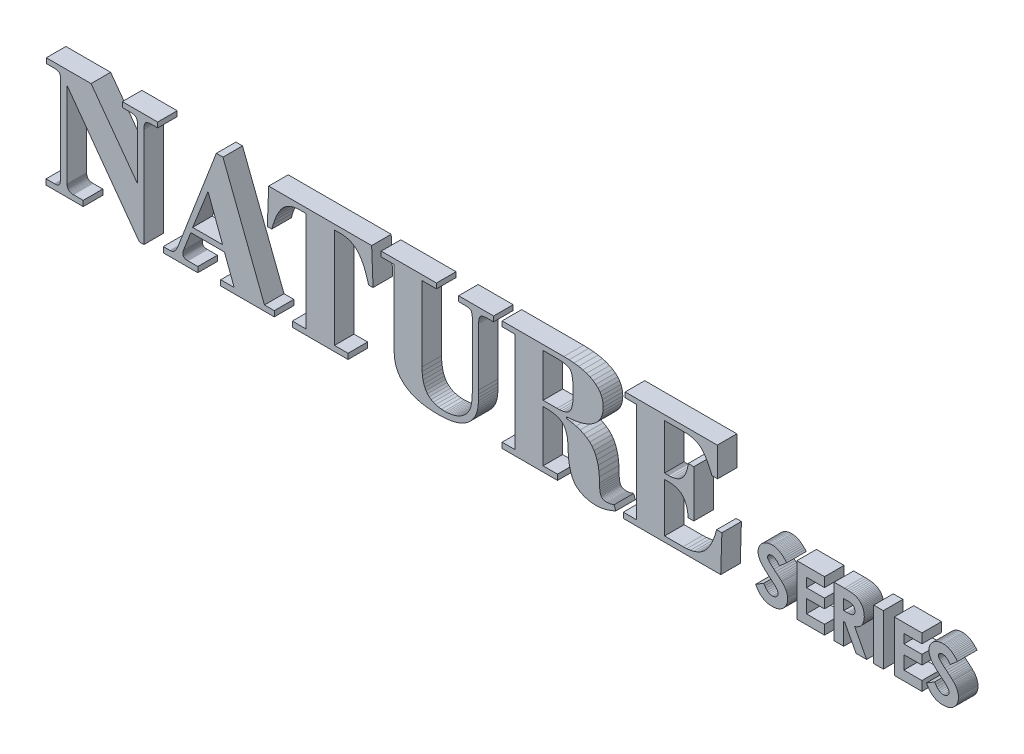
from build123d import *

# Parameters (mm, degrees)
SKETCH2_W              = 1.472974277
SKETCH2_H              = 7.776418359
BOSS_EXTRUDE1_DEPTH    = 3
BOSS_EXTRUDE1_2_DEPTH  = 3
BOSS_EXTRUDE1_3_DEPTH  = 3
BOSS_EXTRUDE1_4_DEPTH  = 3
BOSS_EXTRUDE1_5_DEPTH  = 3
BOSS_EXTRUDE1_6_DEPTH  = 3
BOSS_EXTRUDE1_7_DEPTH  = 3
BOSS_EXTRUDE1_8_DEPTH  = 3
BOSS_EXTRUDE1_9_DEPTH  = 3
BOSS_EXTRUDE1_10_DEPTH = 3
BOSS_EXTRUDE1_11_DEPTH = 3
BOSS_EXTRUDE1_12_DEPTH = 3


with BuildPart() as part:
    # Sketch2 → Boss-Extrude1 (new body)
    with BuildSketch(Plane.XY):
        with Locations((190.243141385, 72.091281059)):
            Rectangle(SKETCH2_W, SKETCH2_H)
    extrude(amount=BOSS_EXTRUDE1_DEPTH)


with BuildPart() as body_2:
    # Sketch2 → Boss-Extrude1 2 (new body)
    with BuildSketch(Plane.XY):
        Polygon((196.902143299, 75.979490238), (192.656556863, 75.979490238), (192.656556863, 68.203071879), (196.902143299, 68.203071879), (196.902143299, 69.654380502), (194.129531141, 69.654380502), (194.129531141, 71.701332768), (196.902143299, 71.701332768), (196.902143299, 73.130975736), (194.129531141, 73.130975736), (194.129531141, 74.528170453), (196.902143299, 74.528170453), align=None)
    extrude(amount=BOSS_EXTRUDE1_2_DEPTH)


with BuildPart() as body_3:
    # Sketch2 → Boss-Extrude1 3 (new body)
    with BuildSketch(Plane.XY):
        Polygon((66.0872556, 69.295395024), (66.011950364, 69.359511059), (65.946226302, 69.432671396), (65.890618724, 69.514264821), (65.845125773, 69.604218894), (65.809745596, 69.702461174), (65.784476338, 69.808919223), (65.769316143, 69.9235206), (65.764263157, 70.046192865), (65.764263157, 83.136511986), (76.851072942, 67.890477006), (77.550708377, 67.890477006), (77.550708377, 83.188672524), (77.555754529, 83.389525472), (77.570840917, 83.571156683), (77.595889439, 83.733487662), (77.630821993, 83.876439919), (77.675560475, 83.999934958), (77.730026785, 84.103894289), (77.79414282, 84.188239418), (77.87105444, 84.25743418), (77.964002008, 84.315977166), (78.073063529, 84.363870718), (78.198317008, 84.40111718), (78.339840449, 84.427718895), (78.497711857, 84.443678206), (78.672009236, 84.448997455), (79.662875267, 84.448997455), (79.662875267, 85.231271566), (74.239066795, 85.231271566), (74.239066795, 84.448997455), (75.334237156, 84.448997455), (75.546569228, 84.443957454), (75.736555277, 84.428886784), (75.904193547, 84.403859447), (76.04948228, 84.368949445), (76.172419719, 84.324230781), (76.273004106, 84.269777455), (76.351233685, 84.205663471), (76.413498502, 84.125833008), (76.466188669, 84.024181956), (76.509302528, 83.900711877), (76.542838419, 83.755424331), (76.566794681, 83.588320883), (76.581169656, 83.399403093), (76.585961683, 83.188672524), (76.585961683, 75.470006918), (69.44532033, 85.231271566), (62.582944783, 85.231271566), (62.582944783, 84.448997455), (63.62596577, 84.448997455), (63.813560052, 84.445525388), (63.981549115, 84.435058291), (64.130005397, 84.417519819), (64.25900134, 84.392833626), (64.368609381, 84.360923368), (64.458901962, 84.3217127), (64.529951522, 84.275125277), (64.587137937, 84.218981364), (64.635740722, 84.147409919), (64.675681776, 84.060408989), (64.706882996, 83.957976622), (64.729266279, 83.840110865), (64.742753525, 83.706809765), (64.747266629, 83.558071371), (64.747266629, 70.211347436), (64.74327419, 70.033860687), (64.731298044, 69.87393249), (64.711339948, 69.731564991), (64.68340166, 69.60676034), (64.647484937, 69.499520683), (64.603591537, 69.409848169), (64.551723216, 69.337744945), (64.487833027, 69.278946696), (64.411637051, 69.229188973), (64.32305543, 69.188473731), (64.222008303, 69.156802922), (64.108415811, 69.134178498), (63.982198096, 69.120602411), (63.843275296, 69.116076615), (62.530795408, 69.116076615), (62.530795408, 68.281664291), (68.241486834, 68.281664291), (68.241486834, 69.116076615), (66.729110311, 69.116076615), (66.599493667, 69.121122767), (66.478938444, 69.136209156), (66.367440833, 69.161257677), (66.264997027, 69.196190231), (66.171603219, 69.240928714), align=None)
    extrude(amount=BOSS_EXTRUDE1_3_DEPTH)


with BuildPart() as body_4:
    # Sketch2 → Boss-Extrude1 4 (new body)
    with BuildSketch(Plane.XY):
        Polygon((109.015866431, 84.252634115), (109.386983788, 84.099902908), (109.732331023, 83.903530716), (110.051988095, 83.663515978), (110.346034959, 83.379857133), (110.619834847, 83.044072864), (110.882374835, 82.647610001), (111.133580824, 82.190474012), (111.373378714, 81.672670365), (111.601694406, 81.094204525), (111.818453799, 80.455081961), (112.023582796, 79.755308139), (112.701653035, 79.755308139), (112.484337928, 85.231271566), (96.686403611, 85.231271566), (96.482153753, 79.755308139), (97.160117952, 79.755308139), (97.375137831, 80.475032881), (97.599273898, 81.129311084), (97.832604452, 81.718140796), (98.07520779, 82.241520063), (98.32716221, 82.699446935), (98.588546008, 83.091919457), (98.859437483, 83.418935678), (99.147847531, 83.692209173), (99.465370476, 83.923444342), (99.811855579, 84.112639818), (100.187152105, 84.259794234), (100.591109315, 84.364906223), (101.023576472, 84.427974419), (101.48440284, 84.448997455), (102.401459422, 84.448997455), (102.401459422, 69.116076615), (100.315305828, 69.116076615), (100.315305828, 68.281664291), (108.868389339, 68.281664291), (108.868389339, 69.116076615), (106.782246907, 69.116076615), (106.782246907, 84.448997455), (107.747094061, 84.448997455), (108.196001525, 84.427179827), (108.618898996, 84.361725901), align=None)
    extrude(amount=BOSS_EXTRUDE1_4_DEPTH)


with BuildPart() as body_5:
    # Sketch2 → Boss-Extrude1 5 (new body)
    with BuildSketch(Plane.XY):
        Polygon((181.957719676, 75.979490238), (177.712122078, 75.979490238), (177.712122078, 68.203071879), (181.957719676, 68.203071879), (181.957719676, 69.654380502), (179.185096356, 69.654380502), (179.185096356, 71.701332768), (181.957719676, 71.701332768), (181.957719676, 73.130975736), (179.185096356, 73.130975736), (179.185096356, 74.528170453), (181.957719676, 74.528170453), align=None)
    extrude(amount=BOSS_EXTRUDE1_5_DEPTH)


with BuildPart() as body_6:
    # Sketch2 → Boss-Extrude1 6 (new body)
    with BuildSketch(Plane.XY):
        Polygon((84.110900761, 69.125771054), (84.025436427, 69.137998054), (83.946283338, 69.155241756), (83.87359028, 69.177574794), (83.807506036, 69.205069803), (83.748179393, 69.237799418), (83.69607024, 69.27343359), (83.651555748, 69.313334486), (83.614789777, 69.357501716), (83.58592619, 69.40593489), (83.565118846, 69.458633616), (83.552521609, 69.515597505), (83.548288338, 69.576826166), (83.548808401, 69.637200161), (83.550316653, 69.69536933), (83.552735186, 69.751261038), (83.555986093, 69.80480265), (83.559991468, 69.855921531), (83.564673403, 69.904545046), (83.569953992, 69.950600561), (83.575831998, 69.993929591), (83.582316956, 70.034366497), (83.589483453, 70.07168439), (83.597406078, 70.105656383), (83.606159417, 70.136055591), (83.615818058, 70.162655125), (83.62645659, 70.1852281), (84.747757449, 73.07966352), (89.906560701, 73.07966352), (91.39727157, 69.116076615), (89.332900833, 69.116076615), (89.332900833, 68.281664291), (97.546946434, 68.281664291), (97.546946434, 69.116076615), (96.043175897, 69.116076615), (89.676185926, 85.570298315), (88.659183816, 85.570298315), (82.835481614, 70.415602875), (82.751945901, 70.214429642), (82.66894138, 70.031882228), (82.586466198, 69.867962584), (82.504518498, 69.722672663), (82.423096426, 69.596014418), (82.342198127, 69.487989801), (82.261821746, 69.398600766), (82.180430817, 69.324091733), (82.092719759, 69.260841526), (81.998766381, 69.208924538), (81.898648492, 69.16841516), (81.792443901, 69.139387786), (81.680230418, 69.121916807), (81.562085853, 69.116076615), (80.519064866, 69.116076615), (80.519064866, 68.281664291), (85.816908934, 68.281664291), (85.816908934, 69.116076615), (84.300168025, 69.116076615), (84.202527555, 69.118488119), align=None)
        Polygon((85.025928377, 73.914176303), (89.624036551, 73.914176303), (87.385793636, 79.855253666), align=None, mode=Mode.SUBTRACT)
    extrude(amount=BOSS_EXTRUDE1_6_DEPTH)


with BuildPart() as body_7:
    # Sketch2 → Boss-Extrude1 7 (new body)
    with BuildSketch(Plane.XY):
        Polygon((187.14751607, 71.931744739), (187.305524027, 72.043141777), (187.448404169, 72.164923482), (187.576193008, 72.297089463), (187.688927059, 72.43963933), (187.785940368, 72.59181663), (187.868118551, 72.754346966), (187.935428804, 72.927199877), (187.987838325, 73.110344904), (188.02531431, 73.303751587), (188.047823956, 73.507389465), (188.055334461, 73.72122808), (188.048490298, 73.926032253), (188.027977075, 74.122690168), (187.993823688, 74.311233068), (187.946059037, 74.491692192), (187.884712019, 74.664098781), (187.809811532, 74.828484077), (187.721386473, 74.98487932), (187.621925505, 75.131167127), (187.513771954, 75.265250485), (187.396865878, 75.387062032), (187.271147333, 75.496534403), (187.136556376, 75.593600236), (186.993033062, 75.678192168), (186.840517449, 75.750242836), (186.669007831, 75.811225247), (186.467061582, 75.862751822), (186.23473923, 75.904849506), (185.972101305, 75.937545244), (185.679208336, 75.960865982), (185.356120852, 75.974838665), (185.002899383, 75.979490238), (183.430693953, 75.979490238), (183.430693953, 68.203071879), (184.903668231, 68.203071879), (184.903668231, 71.495536957), (185.053486063, 71.495536957), (186.800802664, 68.203071879), (188.418225799, 68.203071879), (186.582360184, 71.659865531), (186.785970661, 71.740106226), (186.974343786, 71.830732759), align=None)
        Polygon((184.903668231, 74.538953051), (184.903668231, 72.936062983), (185.37303493, 72.936062983), (185.568092368, 72.939826078), (185.7448692, 72.9511358), (185.903428493, 72.970022805), (186.043833315, 72.996517748), (186.166146733, 73.030651283), (186.270431815, 73.072454066), (186.356751629, 73.121956752), (186.427931977, 73.180305979), (186.488239715, 73.248638818), (186.537646336, 73.326985924), (186.576123331, 73.415377952), (186.603642193, 73.513845558), (186.620174416, 73.622419396), (186.625691492, 73.741130121), (186.622935688, 73.812507678), (186.614688711, 73.881241669), (186.600981218, 73.947330534), (186.581843863, 74.010772709), (186.557307301, 74.071566634), (186.527402188, 74.129710745), (186.492159178, 74.185203481), (186.452378136, 74.237150636), (186.40883862, 74.284669786), (186.361540825, 74.327762687), (186.310484946, 74.366431098), (186.255671179, 74.400676775), (186.197099718, 74.430501475), (186.13477076, 74.455906957), (186.063591908, 74.478136412), (185.976978496, 74.496855953), (185.87495981, 74.512098382), (185.757565139, 74.523896504), (185.624823773, 74.532283121), (185.476764998, 74.537291036), (185.313418104, 74.538953051), align=None, mode=Mode.SUBTRACT)
    extrude(amount=BOSS_EXTRUDE1_7_DEPTH)


with BuildPart() as body_8:
    # Sketch2 → Boss-Extrude1 8 (new body)
    with BuildSketch(Plane.XY):
        Polygon((132.498000037, 69.116076615), (132.498000037, 68.281664291), (140.998816971, 68.281664291), (140.998816971, 69.116076615), (138.78234575, 69.116076615), (138.78234575, 76.991190346), (139.230035633, 76.991190346), (139.717495884, 76.977098752), (140.162995715, 76.934875909), (140.566611667, 76.864599724), (140.92842028, 76.766348104), (141.248498095, 76.640198955), (141.526921651, 76.486230186), (141.763767488, 76.304519701), (141.964125855, 76.085497637), (142.136893439, 75.823306522), (142.282144634, 75.517866691), (142.399953832, 75.169098481), (142.490395425, 74.776922226), (142.553543806, 74.341258263), (142.589473367, 73.862026928), (142.593208834, 73.798639196), (142.596943129, 73.727581436), (142.600676448, 73.64862305), (142.604408986, 73.561533441), (142.608140938, 73.466082013), (142.611872499, 73.362038169), (142.615603865, 73.249171313), (142.661912723, 72.425895161), (142.744936265, 71.680772195), (142.86467449, 71.013726068), (143.021127399, 70.424680436), (143.214294992, 69.913558954), (143.444177267, 69.480285277), (143.710774227, 69.124783061), (143.863242881, 68.966179542), (144.029995455, 68.818148331), (144.210957753, 68.680611716), (144.406055576, 68.553491984), (144.615214729, 68.436711425), (144.838361013, 68.330192326), (145.075420232, 68.233856977), (145.325306147, 68.149231851), (145.583164542, 68.077834899), (145.848995416, 68.019589971), (146.12279877, 67.974420917), (146.404574603, 67.942251588), (146.694322916, 67.923005833), (146.992043709, 67.916607504), (147.159956166, 67.920612326), (147.335851647, 67.932676516), (147.519728394, 67.952874662), (147.71158465, 67.981281351), (147.911418658, 68.017971172), (148.11922866, 68.063018712), (148.335012898, 68.116498559), (148.556129664, 68.177969825), (148.779989185, 68.246806325), (149.00666761, 68.322933864), (149.236241089, 68.406278243), (149.468785772, 68.496765266), (149.704377808, 68.594320735), (149.943093348, 68.698870453), (149.677982088, 69.398600766), (149.584034518, 69.366372827), (149.492141428, 69.336735149), (149.402225105, 69.309611386), (149.314207837, 69.284925193), (149.228011913, 69.262600226), (149.143559621, 69.242560139), (149.06077325, 69.224728588), (148.979884535, 69.209294092), (148.901041317, 69.196437164), (148.824169204, 69.186083803), (148.749193804, 69.178160007), (148.676040723, 69.172591774), (148.60463557, 69.169305103), (148.534903953, 69.16822599), (148.367536552, 69.17619847), (148.215518189, 69.200063971), (148.07877506, 69.239744586), (147.957233357, 69.295162409), (147.850819273, 69.366239533), (147.759459003, 69.452898049), (147.683078738, 69.555060053), (147.618964754, 69.683831646), (147.564511428, 69.846588641), (147.519792764, 70.043254692), (147.484882762, 70.273753455), (147.459855426, 70.538008584), (147.444784755, 70.835943735), (147.439744754, 71.167482563), (147.416327592, 71.982199459), (147.346076237, 72.731392495), (147.228990884, 73.414983764), (147.065071728, 74.032895359), (146.854318965, 74.585049373), (146.596732789, 75.0713679), (146.292313397, 75.491773031), (145.933131133, 75.859212913), (145.507491884, 76.186585963), (145.015475312, 76.473739688), (144.457161082, 76.720521592), (143.832628859, 76.926779182), (143.141958307, 77.092359963), (142.38522909, 77.21711144), (142.38522909, 77.434426547), (143.131307084, 77.489246562), (143.82721221, 77.582829687), (144.472791973, 77.715103092), (145.067893879, 77.885993945), (145.612365433, 78.095429417), (146.106054141, 78.343336677), (146.548807508, 78.629642895), (146.937818344, 78.951894294), (147.266776186, 79.304181856), (147.535755817, 79.686732076), (147.744832018, 80.099771452), (147.894079574, 80.54352648), (147.983573266, 81.018223656), (148.013387879, 81.524089477), (147.981471373, 82.019517065), (147.88577132, 82.48117872), (147.726361916, 82.908849506), (147.50331736, 83.302304489), (147.216711848, 83.661318735), (146.866619577, 83.985667309), (146.453114744, 84.275125277), (145.980029663, 84.529251297), (145.451061856, 84.744073153), (144.866212494, 84.919666607), (144.225482748, 85.056107415), (143.528873791, 85.153471339), (142.776386794, 85.211834136), (141.968022928, 85.231271566), (132.498000037, 85.231271566), (132.498000037, 84.448997455), (134.505862596, 84.448997455), (134.505862596, 69.116076615), align=None)
        Polygon((143.397877977, 80.99822018), (143.389111458, 81.663701854), (143.362861366, 82.248288174), (143.319201897, 82.751981289), (143.25820725, 83.174783345), (143.179951622, 83.516696491), (143.084509208, 83.777722874), (142.971954207, 83.957864643), (142.826382598, 84.087707115), (142.63178056, 84.197783282), (142.388071946, 84.288016798), (142.095180604, 84.358331318), (141.753030385, 84.408650498), (141.36154514, 84.438897992), (140.920648719, 84.448997455), (138.78234575, 84.448997455), (138.78234575, 77.825613832), (140.920648719, 77.825613832), (141.315247053, 77.837865077), (141.671977135, 77.87467088), (141.990766523, 77.936109343), (142.271542778, 78.022258568), (142.514233461, 78.133196658), (142.71876613, 78.269001714), (142.885068348, 78.42975184), (143.021566236, 78.630633296), (143.136860347, 78.886865212), (143.231025073, 79.19844583), (143.304134807, 79.565373393), (143.356263941, 79.987646144), (143.387486866, 80.465262325), align=None, mode=Mode.SUBTRACT)
    extrude(amount=BOSS_EXTRUDE1_8_DEPTH)


with BuildPart() as body_9:
    # Sketch2 → Boss-Extrude1 9 (new body)
    with BuildSketch(Plane.XY):
        Polygon((174.231718579, 76.152351741), (174.068750871, 76.168885331), (173.903543387, 76.174402992), (173.651007789, 76.16257747), (173.410183229, 76.127100641), (173.181072831, 76.067972117), (172.963679719, 75.985191505), (172.758007017, 75.878758417), (172.564057849, 75.748672461), (172.38183534, 75.594933246), (172.218719986, 75.425416569), (172.08060984, 75.246391142), (171.967537509, 75.057856964), (171.879535602, 74.859814035), (171.816636725, 74.652262357), (171.778873486, 74.435201928), (171.766278494, 74.208632748), (171.773896683, 74.048486418), (171.796730941, 73.888309237), (171.834750811, 73.728070356), (171.887925831, 73.567738923), (171.956225541, 73.407284089), (172.039619483, 73.246675003), (172.138077195, 73.085880815), (172.262440146, 72.915367065), (172.423516218, 72.725619862), (172.621339386, 72.516639205), (172.855943625, 72.288425095), (173.127362909, 72.040977532), (173.435631211, 71.774296515), (173.780782508, 71.488382045), (173.962233823, 71.338514781), (174.12442884, 71.199993231), (174.267333779, 71.072877535), (174.390914861, 70.957227831), (174.495138308, 70.853104258), (174.579970339, 70.760566954), (174.645377176, 70.679676059), (174.697767203, 70.603877103), (174.742013121, 70.528108021), (174.778145585, 70.452400054), (174.80619525, 70.376784443), (174.826192771, 70.301292429), (174.838168804, 70.225955252), (174.842154002, 70.150804154), (174.836847704, 70.069353429), (174.820929853, 69.990587662), (174.79440201, 69.91453751), (174.757265737, 69.841233627), (174.709522597, 69.770706669), (174.651174151, 69.70298729), (174.582221961, 69.638106147), (174.505433027, 69.579223807), (174.423585607, 69.529395467), (174.336712504, 69.488622885), (174.244846522, 69.456907818), (174.148020462, 69.434252022), (174.046267129, 69.420657257), (173.939619324, 69.416125277), (173.734160134, 69.437123906), (173.535557734, 69.500119662), (173.343811732, 69.605112351), (173.158921739, 69.752101776), (172.980887363, 69.941087742), (172.809708215, 70.172070055), (172.645383904, 70.44504852), (171.39800702, 69.694095287), (171.527097726, 69.454492767), (171.663631964, 69.233864791), (171.807549596, 69.032180704), (171.958790483, 68.849409852), (172.117294487, 68.685521579), (172.283001468, 68.54048523), (172.455851287, 68.41427015), (172.636531245, 68.30650236), (172.825874106, 68.215323872), (173.023908769, 68.140731173), (173.23066413, 68.082720747), (173.446169089, 68.041289079), (173.670452541, 68.016432656), (173.903543387, 68.008147963), (174.200033028, 68.020856334), (174.479953674, 68.058981316), (174.743303175, 68.122522713), (174.990079385, 68.211480332), (175.220280155, 68.325853976), (175.433903338, 68.46564345), (175.630946785, 68.630848559), (175.80691194, 68.816208304), (175.95571607, 69.01491982), (176.077391784, 69.227081125), (176.171971688, 69.452790236), (176.239488392, 69.692145172), (176.279974501, 69.945243952), (176.293462625, 70.212184594), (176.289601544, 70.350652871), (176.278037827, 70.48605837), (176.258800761, 70.618435455), (176.231919635, 70.747818491), (176.197423738, 70.874241843), (176.155342358, 70.997739877), (176.105704783, 71.118346957), (176.046269805, 71.237459226), (175.976213901, 71.358162632), (175.895540195, 71.480486073), (175.804251811, 71.604458448), (175.702351873, 71.730108653), (175.589843505, 71.857465587), (175.466729832, 71.986558149), (175.401320099, 72.049890753), (175.308716734, 72.134663785), (175.188919737, 72.240875486), (175.041929107, 72.368524099), (174.867744846, 72.517607868), (174.666366953, 72.688125035), (174.437795428, 72.880073842), (174.193458513, 73.088069825), (173.978732104, 73.274219639), (173.793619324, 73.438552574), (173.638123298, 73.581097918), (173.512247149, 73.701884958), (173.415994002, 73.800942984), (173.349366981, 73.878301283), (173.314221045, 73.928350782), (173.284566282, 73.97944978), (173.260372036, 74.031531109), (173.241607651, 74.0845276), (173.228242473, 74.138372086), (173.220245847, 74.192997399), (173.217587117, 74.248336371), (173.221350245, 74.303277738), (173.232660195, 74.356661551), (173.251547819, 74.40849113), (173.278043965, 74.458769794), (173.312179486, 74.507500863), (173.35398523, 74.554687655), (173.403492049, 74.60033349), (173.458311999, 74.641351802), (173.51754863, 74.67614478), (173.581202528, 74.70468138), (173.649274278, 74.726930555), (173.721764465, 74.742861261), (173.798673677, 74.752442451), (173.880002498, 74.75564308), (174.050543323, 74.739285285), (174.22019554, 74.690211641), (174.388961687, 74.608421757), (174.556844303, 74.493915241), (174.723845926, 74.346691705), (174.889969094, 74.166750756), (175.055216346, 73.954092006), (176.152663777, 74.921634809), (175.978929548, 75.11673299), (175.808889163, 75.293538069), (175.642479164, 75.452115651), (175.479636094, 75.592531342), (175.320296495, 75.714850749), (175.164396908, 75.819139475), (175.011873875, 75.905463129), (174.860570734, 75.976639963), (174.706872588, 76.036946334), (174.550810483, 76.086353149), (174.392415465, 76.124831316), align=None)
    extrude(amount=BOSS_EXTRUDE1_9_DEPTH)


with BuildPart() as body_10:
    # Sketch2 → Boss-Extrude1 10 (new body)
    with BuildSketch(Plane.XY):
        Polygon((121.942514403, 69.152007673), (121.605887737, 69.333229075), (121.308483811, 69.55452336), (121.050375066, 69.81581809), (120.829010912, 70.121015804), (120.64169796, 70.474027308), (120.488437968, 70.87477821), (120.369232693, 71.323194119), (120.284083892, 71.81920064), (120.232993322, 72.362723382), (120.215962742, 72.953687953), (120.215962742, 84.448997455), (122.432433963, 84.448997455), (122.432433963, 85.231271566), (113.957624744, 85.231271566), (113.957624744, 84.448997455), (115.939468426, 84.448997455), (115.939468426, 72.866701635), (115.974337228, 72.195648181), (116.078995444, 71.571951424), (116.253520784, 70.995612926), (116.49799096, 70.466634249), (116.812483685, 69.985016956), (117.197076669, 69.550762608), (117.651847625, 69.163872768), (118.173899481, 68.826488802), (118.760421402, 68.540801675), (119.411491296, 68.306887339), (120.127187069, 68.12482175), (120.90758663, 67.994680862), (121.752767884, 67.916540629), (122.662808738, 67.890477006), (123.222646417, 67.901375781), (123.754733009, 67.934020167), (124.258992169, 67.988332257), (124.735347553, 68.064234146), (125.183722815, 68.161647924), (125.604041611, 68.280495687), (125.996227596, 68.420699525), (126.362891596, 68.582779179), (126.70675541, 68.767280418), (127.027894797, 68.974279198), (127.326385515, 69.203851473), (127.602303324, 69.456073198), (127.855723982, 69.731020326), (128.08672325, 70.028768813), (128.20805629, 70.208378933), (128.318825419, 70.397117446), (128.419107176, 70.595060501), (128.508978103, 70.802284248), (128.588514738, 71.018864836), (128.657793623, 71.244878416), (128.716891297, 71.480401137), (128.765290984, 71.740867364), (128.806250458, 72.04543577), (128.839767572, 72.394028445), (128.865840177, 72.786567485), (128.884466125, 73.222974981), (128.895643269, 73.703173027), (128.899369461, 74.227083715), (128.899369461, 83.088715834), (128.905214924, 83.313801267), (128.922698204, 83.516010167), (128.951739637, 83.695341951), (128.992259559, 83.851796031), (129.044178305, 83.985371823), (129.10741621, 84.096068739), (129.181893611, 84.183886195), (129.274729331, 84.254692792), (129.393043362, 84.314390714), (129.536757798, 84.363058455), (129.705794732, 84.400774507), (129.900076257, 84.427617362), (130.119524467, 84.443665514), (130.364061453, 84.448997455), (131.194120555, 84.448997455), (131.194120555, 85.231271566), (125.822355418, 85.231271566), (125.822355418, 84.448997455), (126.661221424, 84.448997455), (126.888709378, 84.444205135), (127.090655172, 84.429829477), (127.267060563, 84.405872434), (127.417927308, 84.372335958), (127.543257164, 84.329222001), (127.643051889, 84.276532517), (127.71731324, 84.214269457), (127.774499655, 84.134193851), (127.823102441, 84.028116453), (127.863043495, 83.896113803), (127.894244715, 83.738262442), (127.916627998, 83.554638909), (127.930115243, 83.345319744), (127.934628348, 83.110381488), (127.934628348, 74.483488529), (127.934628348, 74.227083715), (127.929049408, 73.656598295), (127.9123657, 73.137278423), (127.884656886, 72.66920181), (127.846002631, 72.252446167), (127.7964826, 71.887089207), (127.736176457, 71.573208642), (127.665163865, 71.310882182), (127.581322333, 71.079357644), (127.482510557, 70.857874514), (127.368650826, 70.646354494), (127.239665427, 70.444719286), (127.09547665, 70.252890594), (126.936006783, 70.070790119), (126.761178113, 69.898339565), (126.593252964, 69.751192275), (126.417268642, 69.615143702), (126.233150754, 69.490119063), (126.040824909, 69.376043575), (125.840216713, 69.272842454), (125.631251775, 69.180440918), (125.413855701, 69.098764184), (125.188489198, 69.027719961), (124.955671743, 68.967401516), (124.715402751, 68.917883243), (124.467681634, 68.879239532), (124.212507808, 68.851544776), (123.949880687, 68.834873369), (123.679799686, 68.829299701), (123.187006452, 68.849505169), (122.733146201, 68.910073281), (122.318291371, 69.010931595), align=None)
    extrude(amount=BOSS_EXTRUDE1_10_DEPTH)


with BuildPart() as body_11:
    # Sketch2 → Boss-Extrude1 11 (new body)
    with BuildSketch(Plane.XY):
        Polygon((151.377189998, 84.448997455), (153.146082957, 84.448997455), (153.146082957, 69.116076615), (151.086059861, 69.116076615), (151.086059861, 68.281664291), (166.032157801, 68.281664291), (166.21027158, 73.940206342), (165.401978592, 73.940206342), (165.199488979, 73.227370118), (164.975794612, 72.575196087), (164.730970274, 71.983685614), (164.465090749, 71.452840066), (164.178230819, 70.982660811), (163.870465266, 70.573149215), (163.541868875, 70.224306645), (163.18585958, 69.930286433), (162.792136673, 69.6815001), (162.360779625, 69.477947645), (161.891867904, 69.31962907), (161.385480979, 69.206544373), (160.841698319, 69.138693555), (160.260599393, 69.116076615), (157.422566111, 69.116076615), (157.422566111, 76.626133559), (157.918052147, 76.626133559), (158.341093196, 76.610442464), (158.731072012, 76.56342242), (159.087911078, 76.485153286), (159.411532878, 76.375714922), (159.701859897, 76.235187186), (159.958814616, 76.06364994), (160.18231952, 75.861183041), (160.37734217, 75.623035663), (160.548799232, 75.344356745), (160.696536843, 75.025075801), (160.820401144, 74.665122343), (160.920238272, 74.264425885), (160.995894366, 73.822915938), (161.047215564, 73.340522016), (161.907758387, 73.340522016), (161.907758387, 80.563589965), (161.047215564, 80.563589965), (160.975632925, 80.112855755), (160.883740973, 79.699370448), (160.771467075, 79.323133848), (160.638738595, 78.984145761), (160.485482898, 78.68240599), (160.31162735, 78.417914342), (160.117099314, 78.190670619), (159.900256205, 77.996955303), (159.655814894, 77.833047699), (159.383853288, 77.698945857), (159.084449295, 77.594647823), (158.757680821, 77.520151645), (158.403625773, 77.475455369), (158.022362059, 77.460557045), (157.957663544, 77.460569737), (157.897524832, 77.460658578), (157.841719232, 77.460899719), (157.790020051, 77.461369308), (157.742200598, 77.462143496), (157.698034182, 77.463298433), (157.657294109, 77.464910268), (157.620553489, 77.467024202), (157.584888728, 77.469586248), (157.550295919, 77.47252377), (157.516771158, 77.475764134), (157.48431054, 77.479234703), (157.452910159, 77.482862845), (157.422566111, 77.486575922), (157.422566111, 84.448997455), (160.34747409, 84.448997455), (160.817129344, 84.43356605), (161.25377899, 84.387270405), (161.657426736, 84.31010837), (162.028076293, 84.202077798), (162.365731371, 84.063176541), (162.670395679, 83.893402452), (162.942072928, 83.692753383), (163.196484281, 83.447975516), (163.449449571, 83.145712656), (163.701120512, 82.78596695), (163.951648817, 82.368740547), (164.201186201, 81.894035593), (164.449884376, 81.361854237), (164.697895057, 80.772198627), (165.558437879, 80.772198627), (165.506288504, 85.231271566), (151.377189998, 85.231271566), align=None)
    extrude(amount=BOSS_EXTRUDE1_11_DEPTH)


with BuildPart() as body_12:
    # Sketch2 → Boss-Extrude1 12 (new body)
    with BuildSketch(Plane.XY):
        Polygon((200.764867886, 74.493915241), (200.931869704, 74.346691705), (201.097991505, 74.166750756), (201.263235242, 73.954092006), (202.360693836, 74.921634809), (202.186955506, 75.11673299), (202.016912387, 75.293538069), (201.850501022, 75.452115651), (201.687657952, 75.592531342), (201.528319719, 75.714850749), (201.372422866, 75.819139475), (201.219903934, 75.905463129), (201.068596627, 75.976639963), (200.914895292, 76.036946334), (200.758830584, 76.086353149), (200.600433158, 76.124831316), (200.439733668, 76.152351741), (200.276762771, 76.168885331), (200.111551121, 76.174402992), (199.859060367, 76.16257747), (199.618266788, 76.127100641), (199.389176045, 76.067972117), (199.171793803, 75.985191505), (198.966125722, 75.878758417), (198.772177465, 75.748672461), (198.589954695, 75.594933246), (198.426839342, 75.425416569), (198.288729195, 75.246391142), (198.175656865, 75.057856964), (198.087654957, 74.859814035), (198.02475608, 74.652262357), (197.986992842, 74.435201928), (197.97439785, 74.208632748), (197.98201721, 74.048486418), (198.004854202, 73.888309237), (198.042877195, 73.728070356), (198.096054558, 73.567738923), (198.16435466, 73.407284089), (198.247745867, 73.246675003), (198.346196551, 73.085880815), (198.470562723, 72.915367065), (198.631638112, 72.725619862), (198.82945552, 72.516639205), (199.064047751, 72.288425095), (199.335447606, 72.040977532), (199.64368789, 71.774296515), (199.988801404, 71.488382045), (200.170253273, 71.338514781), (200.332449428, 71.199993231), (200.475355311, 71.072877535), (200.598936361, 70.957227831), (200.703158018, 70.853104258), (200.787985721, 70.760566954), (200.85338491, 70.679676059), (200.905779071, 70.603877103), (200.95002795, 70.528108021), (200.986162399, 70.452400054), (201.014213268, 70.376784443), (201.034211407, 70.301292429), (201.046187667, 70.225955252), (201.050172898, 70.150804154), (201.044866633, 70.069353429), (201.02894901, 69.990587662), (201.002421785, 69.91453751), (200.965286716, 69.841233627), (200.917545561, 69.770706669), (200.859200076, 69.70298729), (200.79025202, 69.638106147), (200.713459538, 69.579223807), (200.631610524, 69.529395467), (200.544736998, 69.488622885), (200.452870983, 69.456907818), (200.3560445, 69.434252022), (200.254289572, 69.420657257), (200.147638221, 69.416125277), (199.942219774, 69.437123906), (199.743645621, 69.500119662), (199.551917908, 69.605112351), (199.367038784, 69.752101776), (199.189010396, 69.941087742), (199.017834893, 70.172070055), (198.853514422, 70.44504852), (197.606137537, 69.694095287), (197.735227657, 69.454492767), (197.871760529, 69.233864791), (198.015676599, 69.032180704), (198.166916315, 68.849409852), (198.325420123, 68.685521579), (198.49112847, 68.54048523), (198.663981805, 68.41427015), (198.844660819, 68.30650236), (199.033999808, 68.215323872), (199.232026107, 68.140731173), (199.438767052, 68.082720747), (199.654249979, 68.041289079), (199.878502223, 68.016432656), (200.111551121, 68.008147963), (200.408048443, 68.020856334), (200.687973644, 68.058981316), (200.951325553, 68.122522713), (201.198103, 68.211480332), (201.428304811, 68.325853976), (201.641929816, 68.46564345), (201.838976844, 68.630848559), (202.014937865, 68.816208304), (202.163739034, 69.01491982), (202.285412763, 69.227081125), (202.379991463, 69.452790236), (202.447507548, 69.692145172), (202.48799343, 69.945243952), (202.501481522, 70.212184594), (202.497621026, 70.350652871), (202.486058676, 70.48605837), (202.466823172, 70.618435455), (202.439943218, 70.747818491), (202.405447516, 70.874241843), (202.363364769, 70.997739877), (202.31372368, 71.118346957), (202.254288083, 71.237459226), (202.184230584, 71.358162632), (202.103554698, 71.480486073), (202.012263938, 71.604458448), (201.91036182, 71.730108653), (201.797851858, 71.857465587), (201.674737566, 71.986558149), (201.609332585, 72.049890753), (201.516733775, 72.134663785), (201.396940944, 72.240875486), (201.249953894, 72.368524099), (201.075772432, 72.517607868), (200.874396361, 72.688125035), (200.645825486, 72.880073842), (200.401493518, 73.088069825), (200.186779866, 73.274219639), (200.001684529, 73.438552574), (199.846207507, 73.581097918), (199.720348801, 73.701884958), (199.624108411, 73.800942984), (199.557486336, 73.878301283), (199.522344534, 73.928350782), (199.492692732, 73.97944978), (199.468500471, 74.031531109), (199.44973729, 74.0845276), (199.436372731, 74.138372086), (199.428376332, 74.192997399), (199.425717635, 74.248336371), (199.42948073, 74.303277738), (199.440790453, 74.356661551), (199.459677458, 74.40849113), (199.4861724, 74.458769794), (199.520305935, 74.507500863), (199.562108718, 74.554687655), (199.611611404, 74.60033349), (199.666431648, 74.641351802), (199.725667595, 74.67614478), (199.78931749, 74.70468138), (199.857379575, 74.726930555), (199.929852092, 74.742861261), (200.006733284, 74.752442451), (200.088021395, 74.75564308), (200.258562805, 74.739285285), (200.428216389, 74.690211641), (200.596984098, 74.608421757), align=None)
    extrude(amount=BOSS_EXTRUDE1_12_DEPTH)


solid = Compound([part.part, body_2.part, body_3.part, body_4.part, body_5.part, body_6.part, body_7.part, body_8.part, body_9.part, body_10.part, body_11.part, body_12.part])
